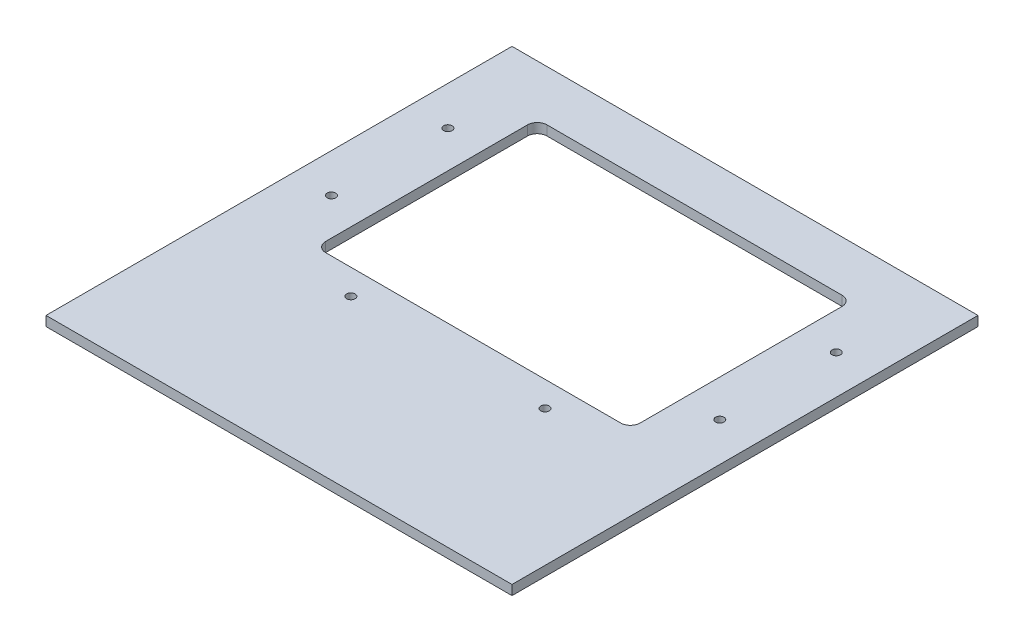
from build123d import *

# Parameters (mm, degrees)
SKETCH1_W           = 304.8
SKETCH1_H           = 304.8
SKETCH1_R           = 2.778125
BOSS_EXTRUDE1_DEPTH = 3.175


with BuildPart() as part:
    # Sketch1 → Boss-Extrude1 (new body, symmetric)
    with BuildSketch(Plane(origin=(0, 0, 0), x_dir=(1, 0, 0), z_dir=(0, 1, 0))):
        Rectangle(SKETCH1_W, SKETCH1_H)
        with Locations((-63.5, -41.91)):
            Circle(SKETCH1_R, mode=Mode.SUBTRACT)
        with Locations((63.5, -41.91)):
            Circle(SKETCH1_R, mode=Mode.SUBTRACT)
        with Locations((127, 8.89)):
            Circle(SKETCH1_R, mode=Mode.SUBTRACT)
        with Locations((127, 85.09)):
            Circle(SKETCH1_R, mode=Mode.SUBTRACT)
        with Locations((-127, 8.89)):
            Circle(SKETCH1_R, mode=Mode.SUBTRACT)
        with Locations((-127, 85.09)):
            Circle(SKETCH1_R, mode=Mode.SUBTRACT)
        with BuildLine():
            Line((-96.511243889, 119.38), (96.511243889, 119.38))
            ThreePointArc((96.511243889, 119.38), (101.00137195, 117.520128061), (102.861243889, 113.03))
            Line((102.861243889, 113.03), (102.861243889, -19.05))
            ThreePointArc((102.861243889, -19.05), (101.00137195, -23.540128061), (96.511243889, -25.4))
            Line((96.511243889, -25.4), (-96.511243889, -25.4))
            ThreePointArc((-96.511243889, -25.4), (-101.00137195, -23.540128061), (-102.861243889, -19.05))
            Line((-102.861243889, -19.05), (-102.861243889, 113.03))
            ThreePointArc((-102.861243889, 113.03), (-101.00137195, 117.520128061), (-96.511243889, 119.38))
        make_face(mode=Mode.SUBTRACT)
    extrude(amount=BOSS_EXTRUDE1_DEPTH, both=True)


solid = part.part
